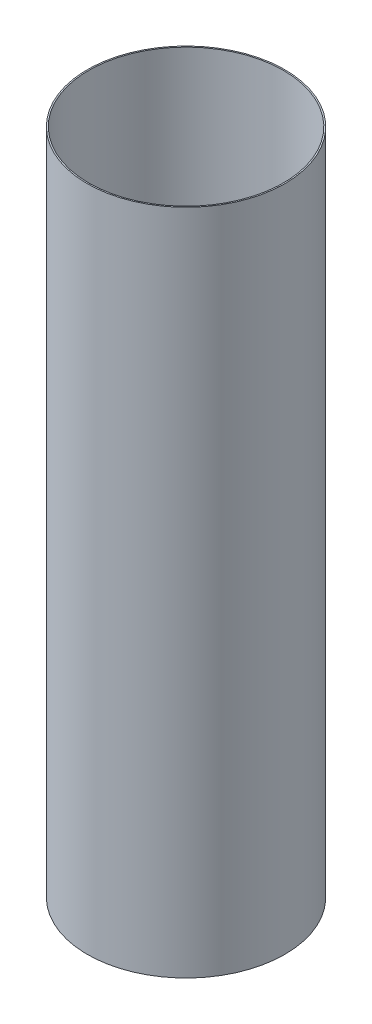
from build123d import *

# Parameters (mm, degrees)
SKETCH1_R           = 74
SKETCH1_R_2         = 73
EXTRUDE_THIN1_DEPTH = 250


with BuildPart() as part:
    # Sketch1 → Extrude-Thin1 (new body, symmetric)
    with BuildSketch(Plane(origin=(0, 0, 0), x_dir=(1, 0, 0), z_dir=(0, 1, 0))):
        Circle(SKETCH1_R)
        Circle(SKETCH1_R_2, mode=Mode.SUBTRACT)
    extrude(amount=EXTRUDE_THIN1_DEPTH, both=True)


solid = part.part
